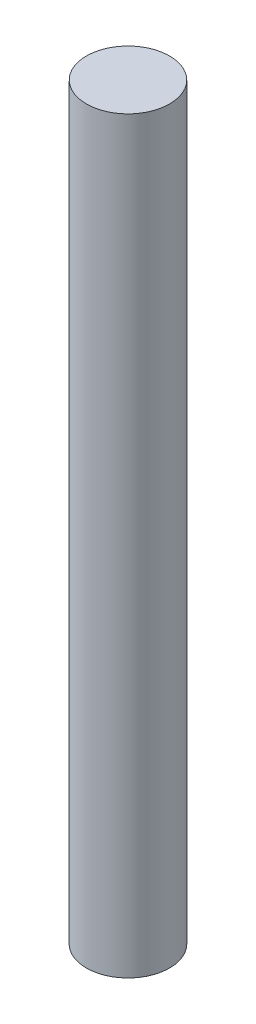
from build123d import *

# Parameters (mm, degrees)
SKETCH1_R           = 1.5875
BOSS_EXTRUDE1_DEPTH = 28.575


with BuildPart() as part:
    # Sketch1 → Boss-Extrude1 (new body)
    with BuildSketch(Plane(origin=(0, 0, 0), x_dir=(1, 0, 0), z_dir=(0, 1, 0))):
        Circle(SKETCH1_R)
    extrude(amount=BOSS_EXTRUDE1_DEPTH)


solid = part.part
